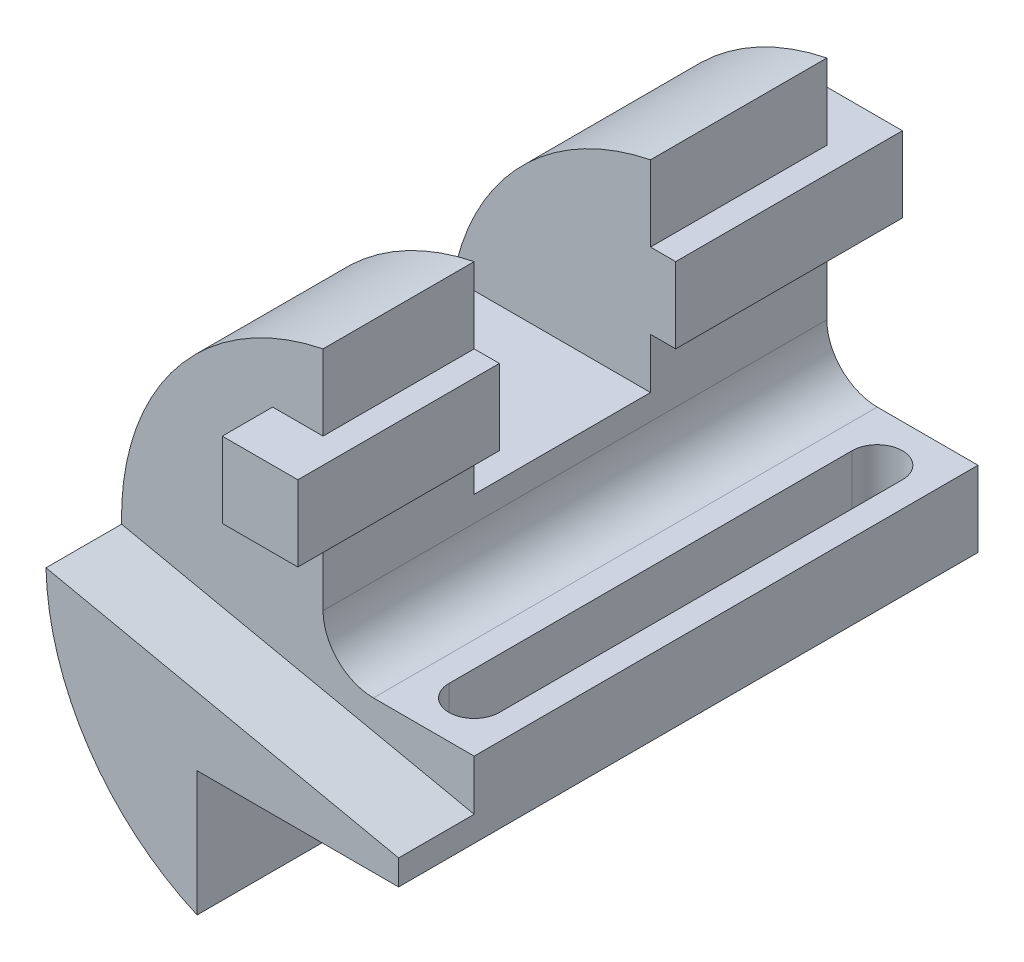
from build123d import *

# Parameters (mm, degrees)
SKETCH1_W                = 10
SKETCH1_H                = 15
BOSS_EXTRUDE1_DEPTH      = 115
SKETCH1_5_W              = 10
SKETCH1_5_H              = 15
CUT_EXTRUDE1_DEPTH       = 15
SKETCH6_W                = 15
SKETCH6_H                = 15
BOSS_EXTRUDE3_DEPTH      = 52.5
BOSS_EXTRUDE3_DEPTH_BACK = 67.5
CUT_EXTRUDE2_REACH       = 47
SKETCH7_W                = 35
SKETCH7_H                = 40
CUT_EXTRUDE3_DEPTH       = 15


with BuildPart() as part:
    # Sketch1 → Boss-Extrude1 (new body)
    with BuildSketch(Plane.XY):
        with BuildLine():
            Line((-10, 79.815551805), (-10, 94.815551805))
            ThreePointArc((-10, 94.815551805), (-39.085961763, 77.007283421), (-49.987139252, 44.691777486))
            Line((-49.987139252, 44.691777486), (20, 29.815551805))
            Line((20, 29.815551805), (20, 39.815551805))
            Line((20, 39.815551805), (0, 39.815551805))
            ThreePointArc((0, 39.815551805), (-7.071067812, 42.744483993), (-10, 49.815551805))
            Line((-10, 49.815551805), (-10, 64.815551805))
            Line((-10, 64.815551805), (-20, 64.815551805))
            Line((-20, 64.815551805), (-20, 79.815551805))
            Line((-20, 79.815551805), (-10, 79.815551805))
        make_face()
        with BuildLine():
            Line((20, 29.815551805), (-49.987139252, 44.691777486))
            ThreePointArc((-49.987139252, 44.691777486), (-41.519738184, 17.96698201), (-20, 0))
            Line((-20, 0), (-20, 24.815551805))
            Line((-20, 24.815551805), (20, 24.815551805))
            Line((20, 24.815551805), (20, 29.815551805))
        make_face()
        with Locations((-15, 72.315551805)):
            Rectangle(SKETCH1_W, SKETCH1_H)
    extrude(amount=-BOSS_EXTRUDE1_DEPTH)

    # Sketch1_5 → Cut-Extrude1 (cut)
    with BuildSketch(Plane.XY):
        with BuildLine():
            Line((-10, 79.815551805), (-10, 94.815551805))
            ThreePointArc((-10, 94.815551805), (-39.085961763, 77.007283421), (-49.987139252, 44.691777486))
            Line((-49.987139252, 44.691777486), (20, 29.815551805))
            Line((20, 29.815551805), (20, 39.815551805))
            Line((20, 39.815551805), (0, 39.815551805))
            ThreePointArc((0, 39.815551805), (-7.071067812, 42.744483993), (-10, 49.815551805))
            Line((-10, 49.815551805), (-10, 64.815551805))
            Line((-10, 64.815551805), (-20, 64.815551805))
            Line((-20, 64.815551805), (-20, 79.815551805))
            Line((-20, 79.815551805), (-10, 79.815551805))
        make_face()
        with Locations((-15, 72.315551805)):
            Rectangle(SKETCH1_5_W, SKETCH1_5_H)
    extrude(amount=-CUT_EXTRUDE1_DEPTH, mode=Mode.SUBTRACT)

    # Sketch6 → Boss-Extrude3 (add, two sides)
    with BuildSketch(Plane.XY.offset(-57.5)) as boss_extrude3_sk:
        with Locations((-12.5, 72.315551805)):
            Rectangle(SKETCH6_W, SKETCH6_H)
    extrude(amount=BOSS_EXTRUDE3_DEPTH)
    extrude(boss_extrude3_sk.sketch, amount=-BOSS_EXTRUDE3_DEPTH_BACK)

    # Sketch7 → Cut-Extrude2 (cut, up to next)
    with BuildSketch(Plane(origin=(-5, 0, 0), x_dir=(0, 0, -1), z_dir=(1, 0, 0)), mode=Mode.PRIVATE) as cut_extrude2_sk1:
        with Locations((62.5, 74.815551805)):
            Rectangle(SKETCH7_W, SKETCH7_H)
    cut_extrude2_tool1 = extrude(cut_extrude2_sk1.sketch, amount=-CUT_EXTRUDE2_REACH, mode=Mode.PRIVATE) & part.part
    add(cut_extrude2_tool1.solids().sort_by_distance((-5, 74.815552, -62.5))[0], mode=Mode.SUBTRACT)

    # Sketch8 → Cut-Extrude3 (cut)
    with BuildSketch(Plane(origin=(0, 39.815551805, 0), x_dir=(1, 0, 0), z_dir=(0, 1, 0))):
        with BuildLine():
            Line((5, 25), (5, 105))
            ThreePointArc((5, 105), (10, 110), (15, 105))
            Line((15, 105), (15, 25))
            ThreePointArc((15, 25), (10, 20), (5, 25))
        make_face()
    extrude(amount=-CUT_EXTRUDE3_DEPTH, mode=Mode.SUBTRACT)


solid = part.part
